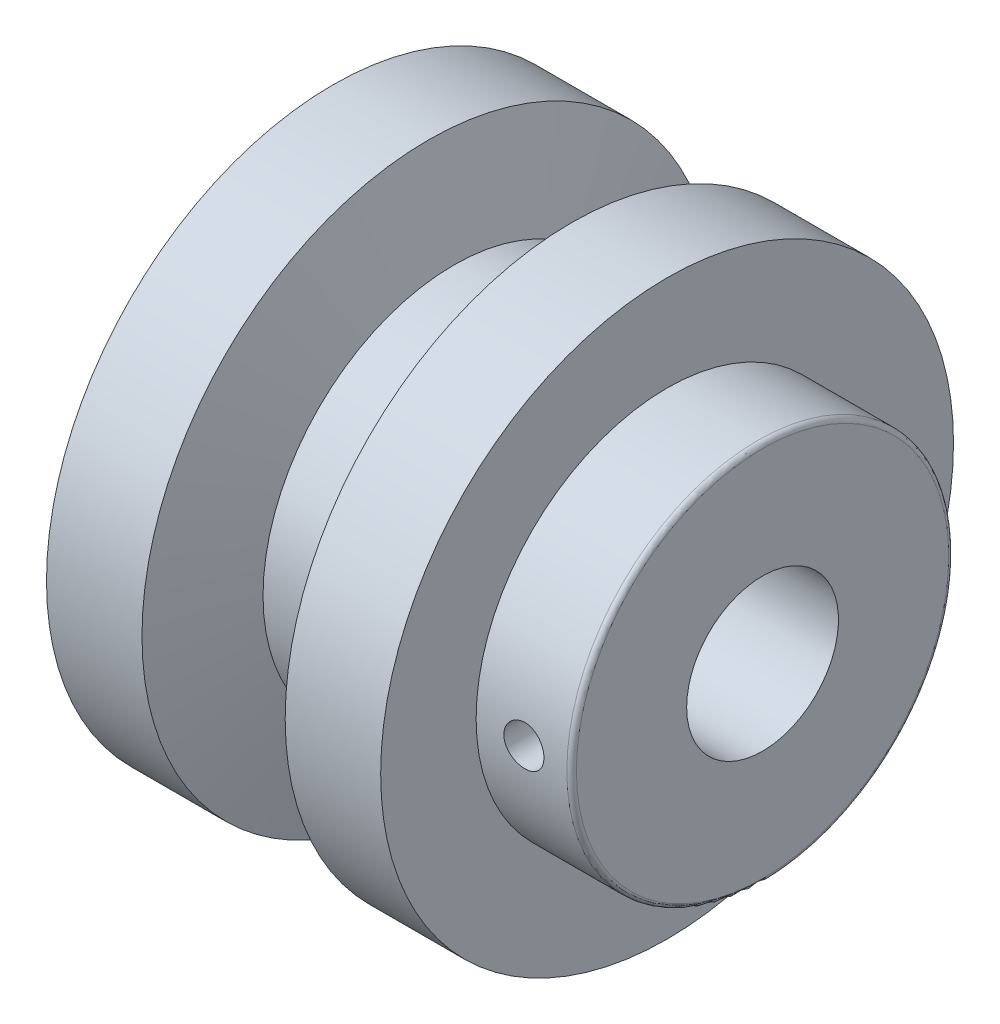
from build123d import *

# Parameters (mm, degrees)
ESBO_O1_W = 2.1
ESBO_O1_H = 30


with BuildPart() as part:
    # Sketch1 → Revolve1 (revolve)
    with BuildSketch(Plane.XY):
        with BuildLine():
            Line((0, -17.95), (0, -30))
            Line((0, -30), (10, -30))
            Line((10, -30), (12.679491924, -20))
            Line((12.679491924, -20), (22.320508076, -20))
            Line((22.320508076, -20), (25, -30))
            Line((25, -30), (35, -30))
            Line((35, -30), (35, -20))
            Line((35, -20), (44.5, -20))
            ThreePointArc((44.5, -20), (44.853553391, -19.853553391), (45, -19.5))
            Line((45, -19.5), (45, -7.95))
            Line((45, -7.95), (2.5, -7.95))
            Line((2.5, -7.95), (0, -17.95))
        make_face()
    revolve(axis=Axis((0, 0, 0), (1, 0, 0)))

    # Esboço1 → Broca de rosquear para tarraxa de M5x0.81 (revolve, cut)
    with BuildSketch(Plane.YZ.offset(40)):
        with Locations((1.05, 15)):
            Rectangle(ESBO_O1_W, ESBO_O1_H)
    revolve(axis=Axis((40, 0, -6.35), (0, 0, 1)), mode=Mode.SUBTRACT)


solid = part.part
